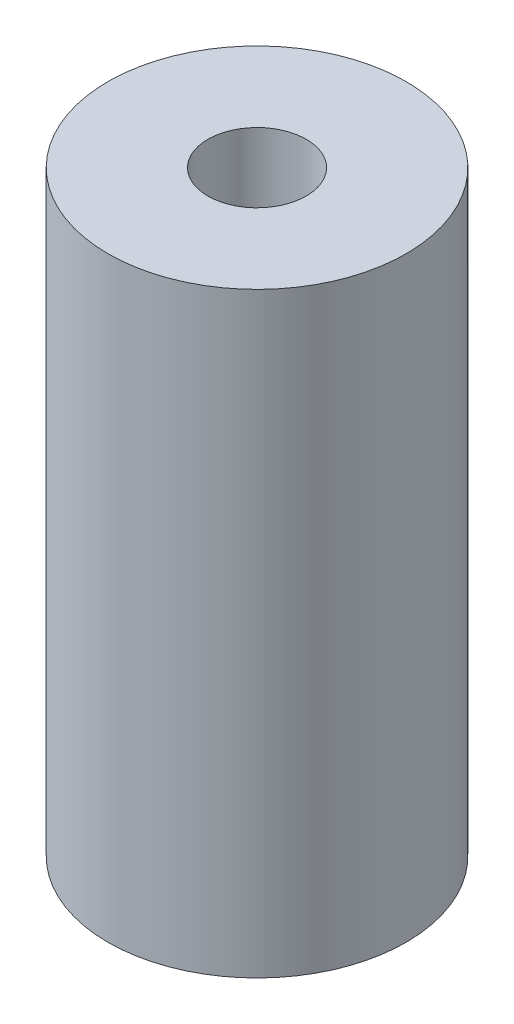
from build123d import *

# Parameters (mm, degrees)
SKETCH1_R             = 5
BOSS_EXTRUDE1_DEPTH   = 20
M4X0_7_TAPPED_HOLE1_D = 3.3


with BuildPart() as part:
    # Sketch1 → Boss-Extrude1 (new body)
    with BuildSketch(Plane(origin=(0, 0, 0), x_dir=(1, 0, 0), z_dir=(0, 1, 0))):
        Circle(SKETCH1_R)
    extrude(amount=BOSS_EXTRUDE1_DEPTH)

    # M4x0.7 Tapped Hole1 (through all)
    with Locations(Plane(origin=(0, 20, 0), x_dir=(1, 0, 0), z_dir=(0, 1, 0))):
        with Locations((0, 0)):
            Hole(M4X0_7_TAPPED_HOLE1_D / 2)


solid = part.part
